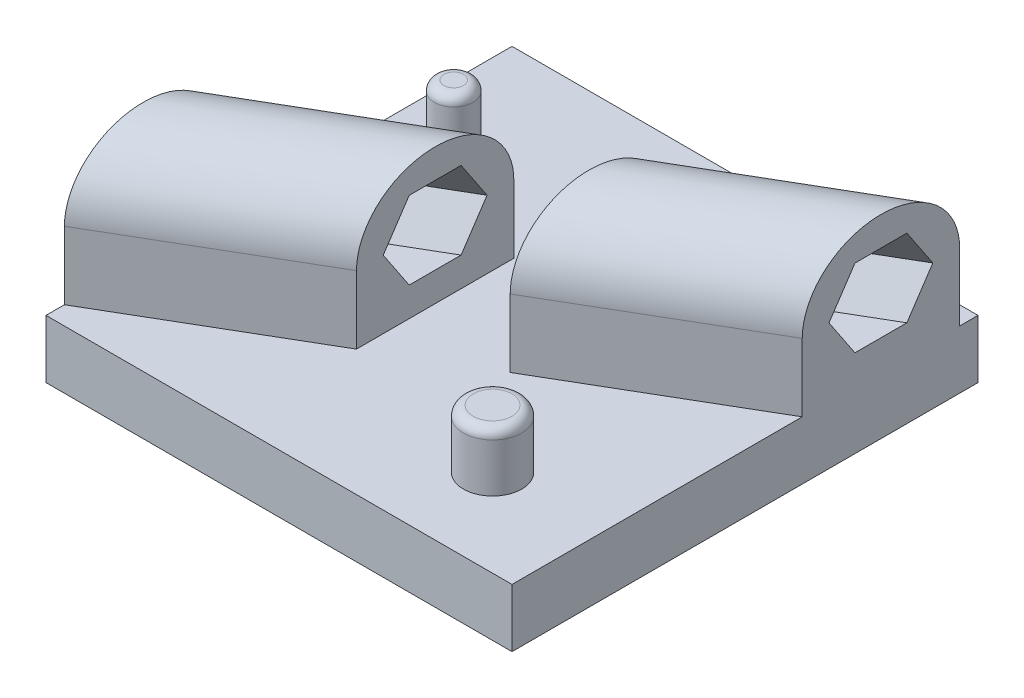
from build123d import *

# Parameters (mm, degrees)
SKETCH1_W                       = 240
SKETCH1_H                       = 30
BOSS_EXTRUDE2_DEPTH             = 120
BOSS_EXTRUDE3_REACH             = 287.178
BOSS_EXTRUDE3_DIRECTION_2_REACH = 247.629
SKETCH7_W                       = 50
SKETCH7_H                       = 70
CUT_EXTRUDE1_DEPTH              = 250
SKETCH8_R                       = 10
SKETCH8_R_2                     = 15
BOSS_EXTRUDE4_DEPTH             = 30
FILLET1_R                       = 5


with BuildPart() as part:
    # Sketch1 → Boss-Extrude2 (new, symmetric)
    with BuildSketch(Plane.XY):
        Rectangle(SKETCH1_W, SKETCH1_H)
    extrude(amount=BOSS_EXTRUDE2_DEPTH, both=True)

    # Boss-Extrude3: up to this plane
    boss_extrude3_end = Plane(origin=(-120, 15, 120), z_dir=(1, 0, 0))
    # Sketch6 → Boss-Extrude3 (add, up to the surface)
    with BuildSketch(Plane(origin=(0, 0, 0), x_dir=(-0.5038710255240862, 0, -0.8637789008984335), z_dir=(0.8637789008984335, 0, -0.5038710255240862)), mode=Mode.PRIVATE) as boss_extrude3_sk1:
        with BuildLine():
            Line((35, 0), (35, 50))
            ThreePointArc((35, 50), (0, 85), (-35, 50))
            Line((-35, 50), (-35, 0))
            Line((-35, 0), (35, 0))
        make_face()
        Polygon((23.094010768, 50), (11.547005384, 70), (-11.547005384, 70), (-23.094010768, 50), (-11.547005384, 30), (11.547005384, 30), align=None, mode=Mode.SUBTRACT)
    boss_extrude3_tool1 = split(extrude(boss_extrude3_sk1.sketch, amount=-BOSS_EXTRUDE3_REACH, mode=Mode.PRIVATE), bisect_by=boss_extrude3_end, keep=Keep.BOTH, mode=Mode.PRIVATE)
    add(boss_extrude3_tool1.solids().sort_by_distance((17.080655, 25, 29.281124))[0])

    # Boss-Extrude3 direction 2: up to this plane
    boss_extrude3_direction_2_end = Plane(origin=(120, 15, 120), z_dir=(-1, 0, 0))
    # Sketch6 → Boss-Extrude3 direction 2 (add, up to the surface)
    with BuildSketch(Plane(origin=(0, 0, 0), x_dir=(-0.5038710255240862, 0, -0.8637789008984335), z_dir=(0.8637789008984335, 0, -0.5038710255240862)), mode=Mode.PRIVATE) as boss_extrude3_direction_2_sk1:
        with BuildLine():
            Line((35, 0), (35, 50))
            ThreePointArc((35, 50), (0, 85), (-35, 50))
            Line((-35, 50), (-35, 0))
            Line((-35, 0), (35, 0))
        make_face()
        Polygon((23.094010768, 50), (11.547005384, 70), (-11.547005384, 70), (-23.094010768, 50), (-11.547005384, 30), (11.547005384, 30), align=None, mode=Mode.SUBTRACT)
    boss_extrude3_direction_2_tool1 = split(extrude(boss_extrude3_direction_2_sk1.sketch, amount=BOSS_EXTRUDE3_DIRECTION_2_REACH, mode=Mode.PRIVATE), bisect_by=boss_extrude3_direction_2_end, keep=Keep.BOTH, mode=Mode.PRIVATE)
    add(boss_extrude3_direction_2_tool1.solids().sort_by_distance((17.080655, 25, 29.281124))[0])

    # Sketch7 → Cut-Extrude1 (cut)
    with BuildSketch(Plane(origin=(0, 0, -70), x_dir=(-1, 0, 0), z_dir=(0, 0, -1))):
        with Locations((0, 50)):
            Rectangle(SKETCH7_W, SKETCH7_H)
    extrude(amount=-CUT_EXTRUDE1_DEPTH, mode=Mode.SUBTRACT)

    # Sketch8 → Boss-Extrude4 (add)
    with BuildSketch(Plane(origin=(0, 15, 0), x_dir=(1, 0, 0), z_dir=(0, 1, 0))):
        with Locations((-90, 60)):
            Circle(SKETCH8_R)
        with Locations((65, -75)):
            Circle(SKETCH8_R_2)
    extrude(amount=BOSS_EXTRUDE4_DEPTH)

    # Fillet1
    fillet1_edges = [part.edges().sort_by_distance(p)[0] for p in [
        (50, 45, 75),
        (-100, 45, -60),
    ]]
    fillet(fillet1_edges, radius=FILLET1_R)


solid = part.part
